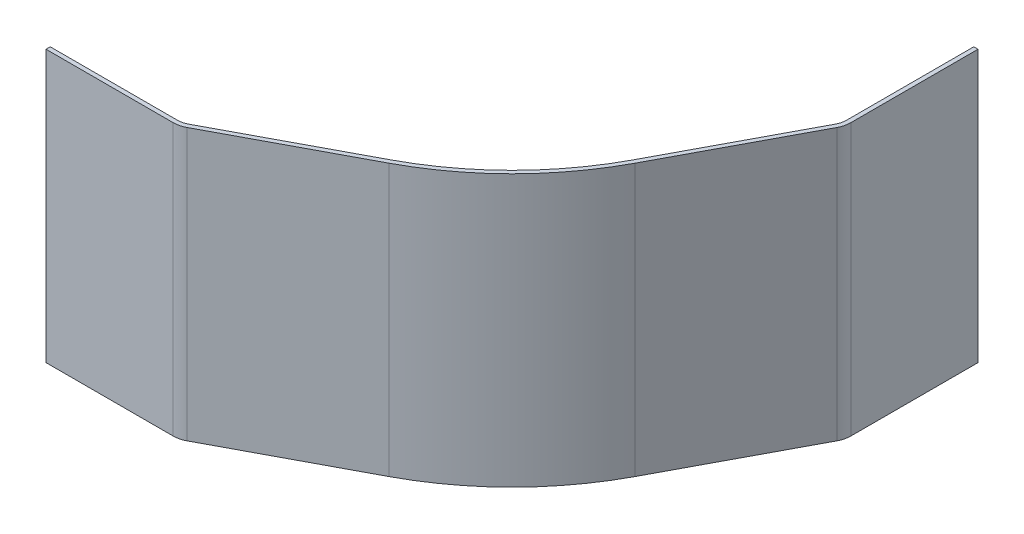
from build123d import *

# Parameters (mm, degrees)
EXTRUDE1_DEPTH = 8


with BuildPart() as part:
    # Sketch1 → Extrude1 (new body, symmetric)
    with BuildSketch(Plane(origin=(0, 0, 0), x_dir=(0, 0, -1), z_dir=(0, -1, 0))):
        with BuildLine():
            Line((-15.234630094, 8.091263553), (-19.368562832, 0.307691101))
            ThreePointArc((-19.368562832, 0.307691101), (-19.466646277, 0.051906982), (-19.5, -0.22))
            Line((-19.5, -0.22), (-19.5, -7.72))
            Line((-19.5, -7.72), (-19.75, -7.72))
            Line((-19.75, -7.72), (-19.75, -0.22))
            ThreePointArc((-19.75, -0.22), (-19.709234338, 0.112330756), (-19.589354573, 0.42495579))
            Line((-19.589354573, 0.42495579), (-15.455421835, 8.208528243))
            ThreePointArc((-15.455421835, 8.208528243), (-12.374368671, 12.374368671), (-8.208528243, 15.455421835))
            Line((-8.208528243, 15.455421835), (-0.42495579, 19.589354573))
            ThreePointArc((-0.42495579, 19.589354573), (-0.112330756, 19.709234338), (0.22, 19.75))
            Line((0.22, 19.75), (7.72, 19.75))
            Line((7.72, 19.75), (7.72, 19.5))
            Line((7.72, 19.5), (0.22, 19.5))
            ThreePointArc((0.22, 19.5), (-0.051906982, 19.466646277), (-0.307691101, 19.368562832))
            Line((-0.307691101, 19.368562832), (-8.091263553, 15.234630094))
            ThreePointArc((-8.091263553, 15.234630094), (-12.197591975, 12.197591975), (-15.234630094, 8.091263553))
        make_face()
    extrude(amount=EXTRUDE1_DEPTH, both=True)


solid = part.part
